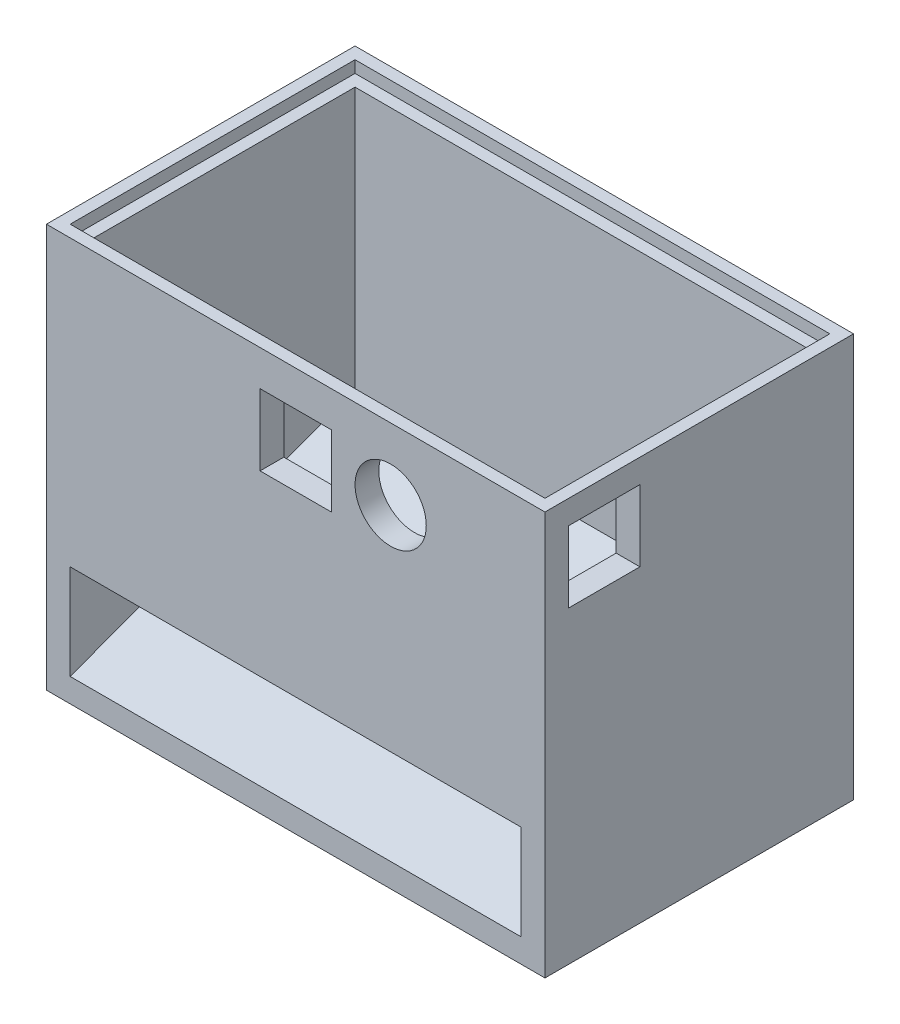
from build123d import *

# Parameters (mm, degrees)
SKETCH1_W           = 105
SKETCH1_H           = 65
BOSS_EXTRUDE1_DEPTH = 5
BOSS_EXTRUDE2_DEPTH = 20
SKETCH3_W           = 105
SKETCH3_H           = 65
SKETCH3_W_2         = 95
SKETCH3_H_2         = 55
BOSS_EXTRUDE3_DEPTH = 60
SKETCH4_W           = 100
SKETCH4_H           = 60
CUT_EXTRUDE1_DEPTH  = 2.5
SKETCH5_W           = 15
SKETCH5_H           = 15
SKETCH5_R           = 7.5
CUT_EXTRUDE3_DEPTH  = 10
SKETCH6_W           = 15
SKETCH6_H           = 15
CUT_EXTRUDE4_DEPTH  = 10
BOSS_EXTRUDE4_DEPTH = 95


with BuildPart() as part:
    # Sketch1 → Boss-Extrude1 (new body)
    with BuildSketch(Plane(origin=(0, 0, 0), x_dir=(1, 0, 0), z_dir=(0, 1, 0))):
        Rectangle(SKETCH1_W, SKETCH1_H)
    extrude(amount=BOSS_EXTRUDE1_DEPTH)

    # Sketch2 → Boss-Extrude2 (add)
    with BuildSketch(Plane(origin=(0, 5, 0), x_dir=(1, 0, 0), z_dir=(0, 1, 0))):
        Polygon((-47.5, -32.5), (-47.5, 27.5), (47.5, 27.5), (47.5, -32.5), (52.5, -32.5), (52.5, 32.5), (-52.5, 32.5), (-52.5, -32.5), align=None)
    extrude(amount=BOSS_EXTRUDE2_DEPTH)

    # Sketch3 → Boss-Extrude3 (add)
    with BuildSketch(Plane(origin=(0, 25, 0), x_dir=(1, 0, 0), z_dir=(0, 1, 0))):
        Rectangle(SKETCH3_W, SKETCH3_H)
        Rectangle(SKETCH3_W_2, SKETCH3_H_2, mode=Mode.SUBTRACT)
    extrude(amount=BOSS_EXTRUDE3_DEPTH)

    # Sketch4 → Cut-Extrude1 (cut)
    with BuildSketch(Plane(origin=(0, 85, 0), x_dir=(1, 0, 0), z_dir=(0, 1, 0))):
        Rectangle(SKETCH4_W, SKETCH4_H)
    extrude(amount=-CUT_EXTRUDE1_DEPTH, mode=Mode.SUBTRACT)

    # Sketch5 → Cut-Extrude3 (cut)
    with BuildSketch(Plane.XY.offset(32.5)):
        with Locations((0, 70)):
            Rectangle(SKETCH5_W, SKETCH5_H)
        with Locations((20, 70)):
            Circle(SKETCH5_R)
    extrude(amount=-CUT_EXTRUDE3_DEPTH, mode=Mode.SUBTRACT)

    # Sketch6 → Cut-Extrude4 (cut)
    with BuildSketch(Plane(origin=(52.5, 0, 0), x_dir=(0, 0, -1), z_dir=(1, 0, 0))):
        with Locations((-20, 72.5)):
            Rectangle(SKETCH6_W, SKETCH6_H)
    extrude(amount=-CUT_EXTRUDE4_DEPTH, mode=Mode.SUBTRACT)

    # Sketch10 → Boss-Extrude4 (add)
    with BuildSketch(Plane(origin=(-47.5, 0, 0), x_dir=(0, 0, -1), z_dir=(1, 0, 0))):
        Polygon((-32.5, 5), (27.5, 27.267325642), (27.5, 5), align=None)
    extrude(amount=BOSS_EXTRUDE4_DEPTH)


solid = part.part
